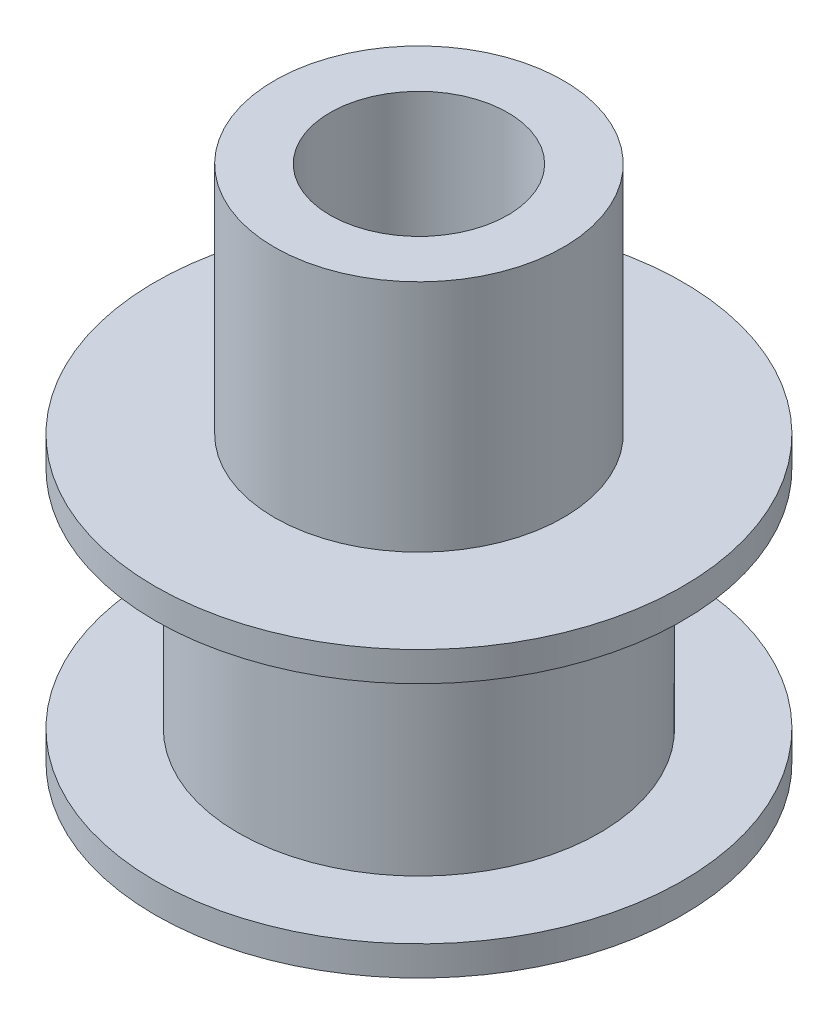
from build123d import *

# Parameters (mm, degrees)
SKETCH1_R           = 8.9
BOSS_EXTRUDE1_DEPTH = 1
SKETCH2_R           = 6.1
BOSS_EXTRUDE2_DEPTH = 7.6
SKETCH3_R           = 8.9
BOSS_EXTRUDE3_DEPTH = 1
SKETCH4_R           = 4.875
BOSS_EXTRUDE4_DEPTH = 7.9
CUT_EXTRUDE1_REACH  = 19.5
SKETCH5_R           = 3


with BuildPart() as part:
    # Sketch1 → Boss-Extrude1 (new body)
    with BuildSketch(Plane(origin=(0, 0, 0), x_dir=(1, 0, 0), z_dir=(0, 1, 0))):
        Circle(SKETCH1_R)
    extrude(amount=BOSS_EXTRUDE1_DEPTH)

    # Sketch2 → Boss-Extrude2 (add)
    with BuildSketch(Plane(origin=(0, 1, 0), x_dir=(1, 0, 0), z_dir=(0, 1, 0))):
        Circle(SKETCH2_R)
    extrude(amount=BOSS_EXTRUDE2_DEPTH)

    # Sketch3 → Boss-Extrude3 (add)
    with BuildSketch(Plane(origin=(0, 8.6, 0), x_dir=(1, 0, 0), z_dir=(0, 1, 0))):
        Circle(SKETCH3_R)
    extrude(amount=BOSS_EXTRUDE3_DEPTH)

    # Sketch4 → Boss-Extrude4 (add)
    with BuildSketch(Plane(origin=(0, 9.6, 0), x_dir=(1, 0, 0), z_dir=(0, 1, 0))):
        Circle(SKETCH4_R)
    extrude(amount=BOSS_EXTRUDE4_DEPTH)

    # Sketch5 → Cut-Extrude1 (cut, up to next)
    with BuildSketch(Plane(origin=(0, 17.5, 0), x_dir=(1, 0, 0), z_dir=(0, 1, 0)), mode=Mode.PRIVATE) as cut_extrude1_sk1:
        Circle(SKETCH5_R)
    cut_extrude1_tool1 = extrude(cut_extrude1_sk1.sketch, amount=-CUT_EXTRUDE1_REACH, mode=Mode.PRIVATE) & part.part
    add(cut_extrude1_tool1.solids().sort_by_distance((0, 17.5, 0))[0], mode=Mode.SUBTRACT)


solid = part.part
